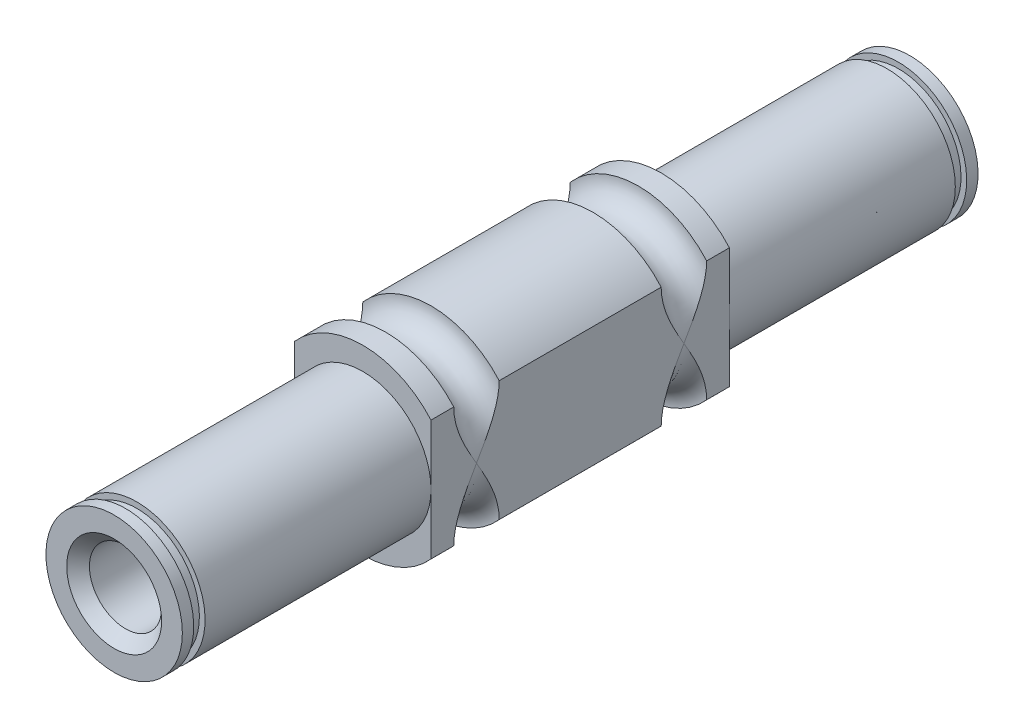
from build123d import *

# Parameters (mm, degrees)
SKETCH1_R               = 8
BOSS_EXTRUDE1_DEPTH     = 26.25
SKETCH2_R               = 6
BOSS_EXTRUDE2_DEPTH     = 21.875
SKETCH3_R               = 6
BOSS_EXTRUDE3_DEPTH     = 21.875
CUT_EXTRUDE4_DEPTH      = 22.875
CUT_EXTRUDE4_DEPTH_BACK = 49.125
SKETCH7_W               = 1
SKETCH7_H               = 0.5
SKETCH9_R               = 3.175
CUT_EXTRUDE5_DEPTH      = 71
CHAMFER1_SIZE           = 1


with BuildPart() as part:
    # Sketch1 → Boss-Extrude1 (new body)
    with BuildSketch(Plane.XY):
        Circle(SKETCH1_R)
    extrude(amount=BOSS_EXTRUDE1_DEPTH)

    # Sketch2 → Boss-Extrude2 (add)
    with BuildSketch(Plane(origin=(0, 0, 0), x_dir=(-1, 0, 0), z_dir=(0, 0, -1))):
        Circle(SKETCH2_R)
    extrude(amount=BOSS_EXTRUDE2_DEPTH)

    # Sketch3 → Boss-Extrude3 (add)
    with BuildSketch(Plane.XY.offset(26.25)):
        Circle(SKETCH3_R)
    extrude(amount=BOSS_EXTRUDE3_DEPTH)

    # Sketch5 → Cut-Extrude4 (cut, two sides)
    with BuildSketch(Plane(origin=(0, 0, 0), x_dir=(-1, 0, 0), z_dir=(0, 0, -1))) as cut_extrude4_sk:
        with BuildLine():
            Line((-6, -5.291502622), (-6, 5.291502622))
            ThreePointArc((-6, 5.291502622), (-8, 0), (-6, -5.291502622))
        make_face()
        with BuildLine():
            ThreePointArc((8, 0), (7.483314774, 2.828427125), (6, 5.291502622))
            Line((6, 5.291502622), (6, -5.291502622))
            ThreePointArc((6, -5.291502622), (7.483314774, -2.828427125), (8, 0))
        make_face()
    extrude(amount=CUT_EXTRUDE4_DEPTH, mode=Mode.SUBTRACT)
    extrude(cut_extrude4_sk.sketch, amount=-CUT_EXTRUDE4_DEPTH_BACK, mode=Mode.SUBTRACT)

    # Sketch7 → Cut-Revolve1 (revolve, cut)
    with BuildSketch(Plane(origin=(0, 0, 0), x_dir=(0, 0, -1), z_dir=(1, 0, 0))):
        with Locations((20.375, 5.75)):
            Rectangle(SKETCH7_W, SKETCH7_H)
        with Locations((-46.625, 5.75)):
            Rectangle(SKETCH7_W, SKETCH7_H)
    revolve(axis=Axis((0, 0, 48.125), (0, 0, -1)), mode=Mode.SUBTRACT)

    # Sketch8 → Cut-Revolve2 (revolve, cut)
    with BuildSketch(Plane(origin=(0, 0, 0), x_dir=(0, 0, -1), z_dir=(1, 0, 0))):
        with BuildLine():
            Line((-24.25, 8), (-20.25, 8))
            ThreePointArc((-20.25, 8), (-22.25, 6), (-24.25, 8))
        make_face()
        with BuildLine():
            Line((-6, 8), (-2, 8))
            ThreePointArc((-2, 8), (-4, 6), (-6, 8))
        make_face()
    revolve(axis=Axis((0, 0, 48.125), (0, 0, -1)), mode=Mode.SUBTRACT)

    # Sketch9 → Cut-Extrude5 (cut, through all)
    with BuildSketch(Plane.XY.offset(48.125)):
        Circle(SKETCH9_R)
    extrude(amount=-CUT_EXTRUDE5_DEPTH, mode=Mode.SUBTRACT)

    # Chamfer1
    chamfer1_edges = [part.edges().sort_by_distance(p)[0] for p in [
        (-3.175, 0, -21.875),
        (-3.175, 0, 48.125),
    ]]
    chamfer(chamfer1_edges, length=CHAMFER1_SIZE)


solid = part.part
